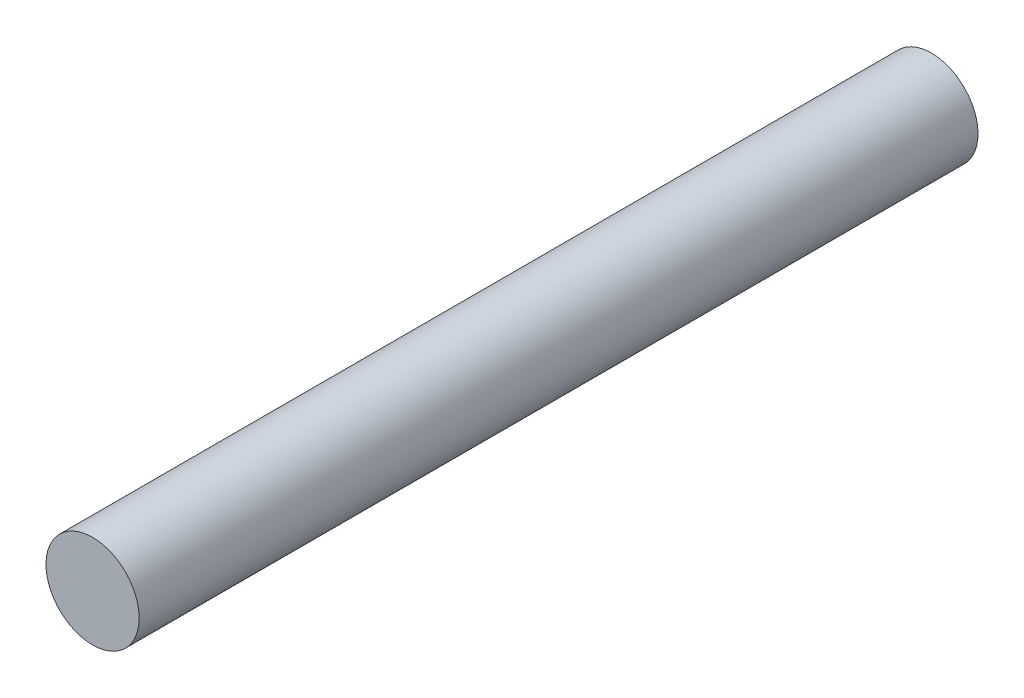
from build123d import *

# Parameters (mm, degrees)
SKETCH3_W = 90
SKETCH3_H = 5


with BuildPart() as part:
    # Sketch3 → Revolve1 (revolve)
    with BuildSketch(Plane(origin=(0, 0, 0), x_dir=(0, 0, -1), z_dir=(1, 0, 0))):
        with Locations((0, 2.5)):
            Rectangle(SKETCH3_W, SKETCH3_H)
    revolve(axis=Axis((0, 0, 45), (0, 0, -1)))


solid = part.part
